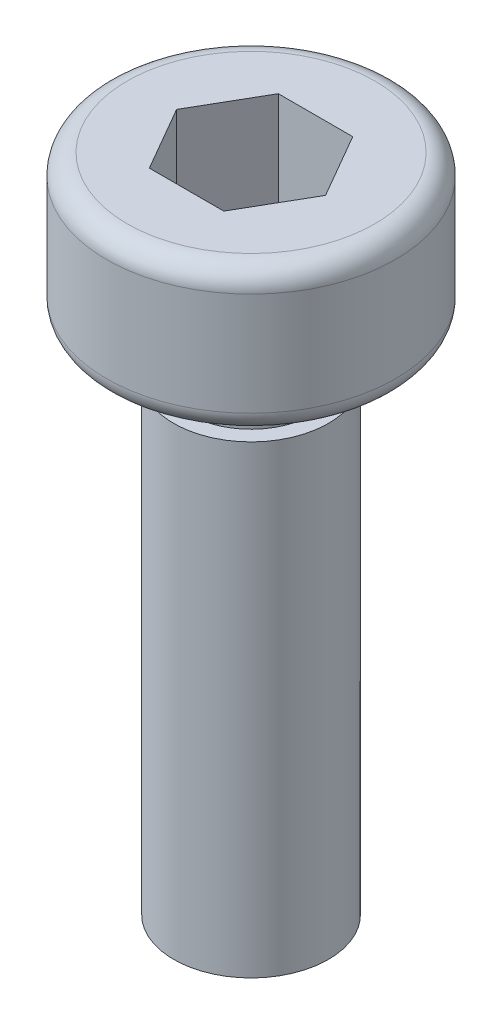
from build123d import *

# Parameters (mm, degrees)
CUT_EXTRUDE_1_DEPTH = 2


with BuildPart() as part:
    # 草图1 → 旋转1 (revolve)
    with BuildSketch(Plane.XY):
        with BuildLine():
            Line((0, 12.8), (-2.4, 12.8))
            ThreePointArc((-2.4, 12.8), (-2.682842712, 12.682842712), (-2.8, 12.4))
            Line((-2.8, 12.4), (-2.8, 10.4))
            ThreePointArc((-2.8, 10.4), (-2.682842712, 10.117157288), (-2.4, 10))
            Line((-2.4, 10), (-1.2, 10))
            Line((-1.2, 10), (-1.2, 9))
            Line((-1.2, 9), (-1.5, 9))
            Line((-1.5, 9), (-1.5, 0))
            Line((-1.5, 0), (0, 0))
            Line((0, 0), (0, 12.8))
        make_face()
    revolve(axis=Axis((0, 0, 0), (0, 1, 0)))

    # 草图2 → 切除-拉伸1 (cut)
    with BuildSketch(Plane(origin=(0, 12.8, 0), x_dir=(1, 0, 0), z_dir=(0, 1, 0))):
        Polygon((-0.721687836, 1.25), (-1.443375673, 0), (-0.721687836, -1.25), (0.721687836, -1.25), (1.443375673, 0), (0.721687836, 1.25), align=None)
    extrude(amount=-CUT_EXTRUDE_1_DEPTH, mode=Mode.SUBTRACT)


solid = part.part
